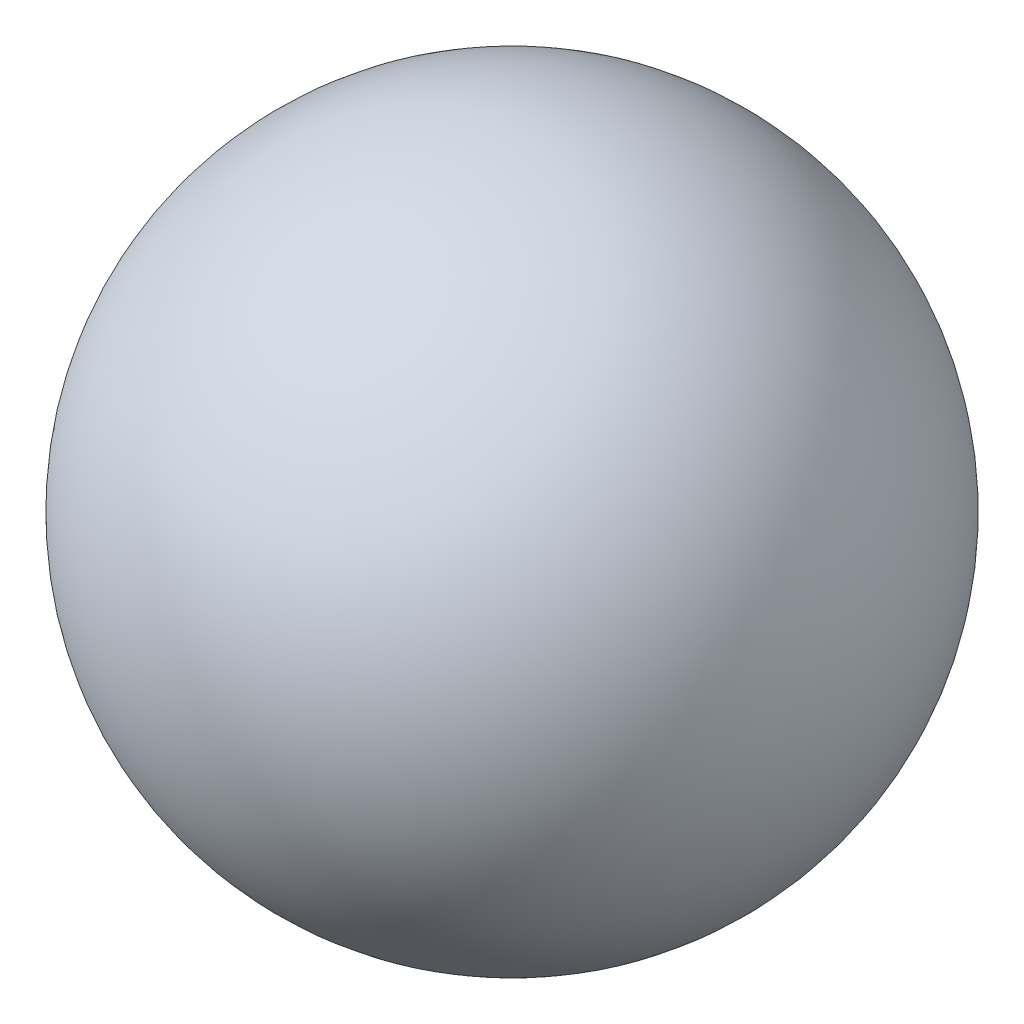
from build123d import *


with BuildPart() as part:
    # Sketch1 → Revolve5 (revolve)
    with BuildSketch(Plane.XY):
        with BuildLine():
            Line((0, 109.15), (0, -109.15))
            ThreePointArc((0, -109.15), (-109.15, 0), (0, 109.15))
        make_face()
    revolve(axis=Axis((0, 109.15, 0), (0, -1, 0)))


solid = part.part
